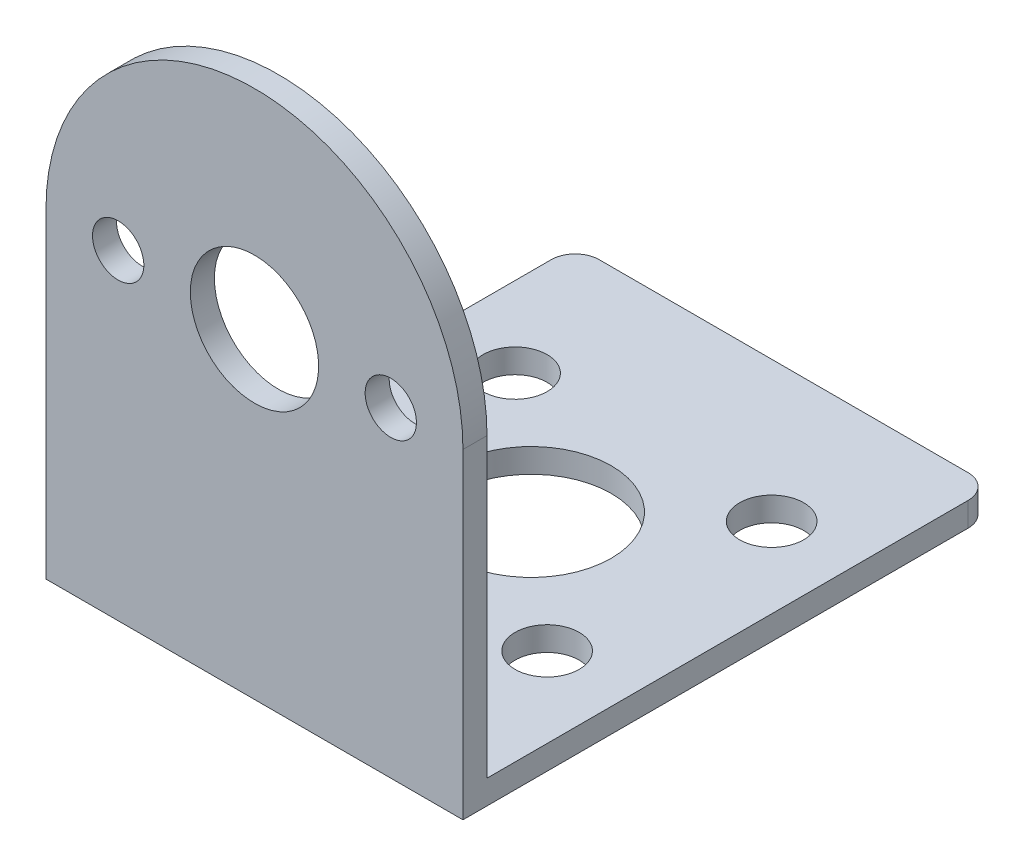
from build123d import *

# Parameters (mm, degrees)
BOSS_EXTRUDE1_DEPTH = 1.5
SKETCH2_R           = 4
SKETCH2_R_2         = 1.6
CUT_EXTRUDE1_DEPTH  = 2.5
SKETCH3_W           = 26
SKETCH3_H           = 1.5
BOSS_EXTRUDE4_DEPTH = 31.5
SKETCH4_R           = 5
SKETCH4_R_2         = 2
CUT_EXTRUDE2_DEPTH  = 34
FILLET1_R           = 1.5


with BuildPart() as part:
    # Sketch1 → Boss-Extrude1 (new body)
    with BuildSketch(Plane.XY):
        with BuildLine():
            Line((0, 0), (26, 0))
            Line((26, 0), (26, 20))
            ThreePointArc((26, 20), (13, 33), (0, 20))
            Line((0, 20), (0, 0))
        make_face()
    extrude(amount=BOSS_EXTRUDE1_DEPTH)

    # Sketch2 → Cut-Extrude1 (cut, through all)
    with BuildSketch(Plane(origin=(0, 0, 0), x_dir=(-1, 0, 0), z_dir=(0, 0, -1))):
        with Locations((-13, 20)):
            Circle(SKETCH2_R)
        with Locations((-21.5, 20)):
            Circle(SKETCH2_R_2)
        with Locations((-4.5, 20)):
            Circle(SKETCH2_R_2)
    extrude(amount=-CUT_EXTRUDE1_DEPTH, mode=Mode.SUBTRACT)

    # Sketch3 → Boss-Extrude4 (add)
    with BuildSketch(Plane(origin=(0, 0, 0), x_dir=(-1, 0, 0), z_dir=(0, 0, -1))):
        with Locations((-13, 0.75)):
            Rectangle(SKETCH3_W, SKETCH3_H)
    extrude(amount=BOSS_EXTRUDE4_DEPTH)

    # Sketch4 → Cut-Extrude2 (cut, through all)
    with BuildSketch(Plane.XZ):
        with Locations((13, -15.75)):
            Circle(SKETCH4_R)
        with Locations((5, -8.75)):
            Circle(SKETCH4_R_2)
        with Locations((21, -8.75)):
            Circle(SKETCH4_R_2)
        with Locations((21, -22.75)):
            Circle(SKETCH4_R_2)
        with Locations((5, -22.75)):
            Circle(SKETCH4_R_2)
    extrude(amount=-CUT_EXTRUDE2_DEPTH, mode=Mode.SUBTRACT)

    # Fillet1
    fillet1_edges = [part.edges().sort_by_distance(p)[0] for p in [
        (26, 0.75, -31.5),
        (0, 0.75, -31.5),
    ]]
    fillet(fillet1_edges, radius=FILLET1_R)


solid = part.part
